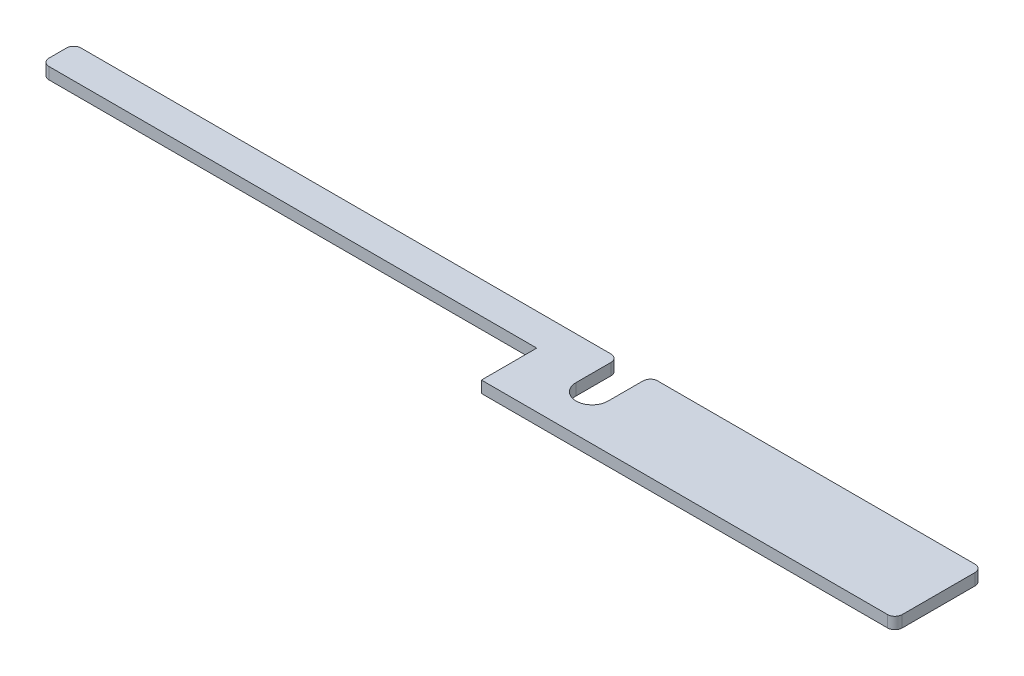
from build123d import *

# Parameters (mm, degrees)
BOSS_EXTRUDE1_DEPTH = 1.016
FILLET1_R           = 0.635


with BuildPart() as part:
    # Sketch1 → Boss-Extrude1 (new body)
    with BuildSketch(Plane(origin=(0, 0, 0), x_dir=(1, 0, 0), z_dir=(0, 1, 0))):
        with BuildLine():
            Line((0, 0), (-36.068, 0))
            Line((-36.068, 0), (-36.068, 4.826))
            Line((-36.068, 4.826), (-79.248, 4.826))
            Line((-79.248, 4.826), (-79.248, 7.62))
            Line((-79.248, 7.62), (-31.75, 7.62))
            Line((-31.75, 7.62), (-31.75, 3.937))
            ThreePointArc((-31.75, 3.937), (-30.353, 2.54), (-28.956, 3.937))
            Line((-28.956, 3.937), (-28.956, 7.62))
            Line((-28.956, 7.62), (0, 7.62))
            Line((0, 7.62), (0, 0))
        make_face()
    extrude(amount=BOSS_EXTRUDE1_DEPTH)

    # Fillet1
    fillet1_edges = [part.edges().sort_by_distance(p)[0] for p in [
        (0, 0.508, 0),
        (-79.248, 0.508, -4.826),
        (-79.248, 0.508, -7.62),
        (-31.75, 0.508, -7.62),
        (-28.956, 0.508, -7.62),
        (0, 0.508, -7.62),
    ]]
    fillet(fillet1_edges, radius=FILLET1_R)


solid = part.part
